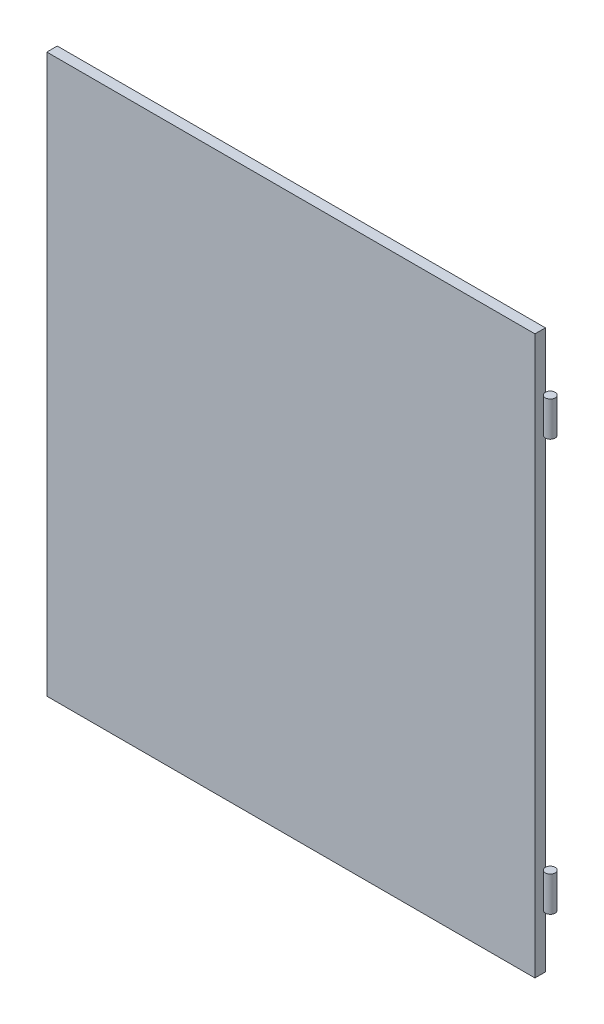
from build123d import *

# Parameters (mm, degrees)
CROQUIS1_W              = 700
CROQUIS1_H              = 800
SALIENTE_EXTRUIR1_DEPTH = 15
CROQUIS2_W              = 690
CROQUIS2_H              = 790
CORTAR_EXTRUIR1_DEPTH   = 10
CROQUIS4_R              = 7
SALIENTE_EXTRUIR2_DEPTH = 800
CROQUIS5_W              = 52.334902761
CROQUIS5_H              = 80
CROQUIS5_H_2            = 540
CORTAR_EXTRUIR2_DEPTH   = 25


with BuildPart() as part:
    # Croquis1 → Saliente-Extruir1 (new body)
    with BuildSketch(Plane.XY):
        with Locations((350, -400)):
            Rectangle(CROQUIS1_W, CROQUIS1_H)
    extrude(amount=SALIENTE_EXTRUIR1_DEPTH)

    # Croquis2 → Cortar-Extruir1 (cut)
    with BuildSketch(Plane(origin=(0, 0, 0), x_dir=(-1, 0, 0), z_dir=(0, 0, -1))):
        with Locations((-350, -400)):
            Rectangle(CROQUIS2_W, CROQUIS2_H)
    extrude(amount=-CORTAR_EXTRUIR1_DEPTH, mode=Mode.SUBTRACT)


with BuildPart() as body_2:
    # Croquis4 → Saliente-Extruir2 (new body)
    with BuildSketch(Plane(origin=(0, 0, 0), x_dir=(1, 0, 0), z_dir=(0, 1, 0))):
        with Locations((707, 0)):
            Circle(CROQUIS4_R)
    extrude(amount=-SALIENTE_EXTRUIR2_DEPTH)

    # Croquis5 → Cortar-Extruir2 (cut)
    with BuildSketch(Plane.XY.offset(15)):
        with Locations((726.167451381, -40)):
            Rectangle(CROQUIS5_W, CROQUIS5_H)
        with Locations((726.167451381, -760)):
            Rectangle(CROQUIS5_W, CROQUIS5_H)
        with Locations((726.167451381, -400)):
            Rectangle(CROQUIS5_W, CROQUIS5_H_2)
    extrude(amount=-CORTAR_EXTRUIR2_DEPTH, mode=Mode.SUBTRACT)


solid = Compound([part.part, body_2.part])
